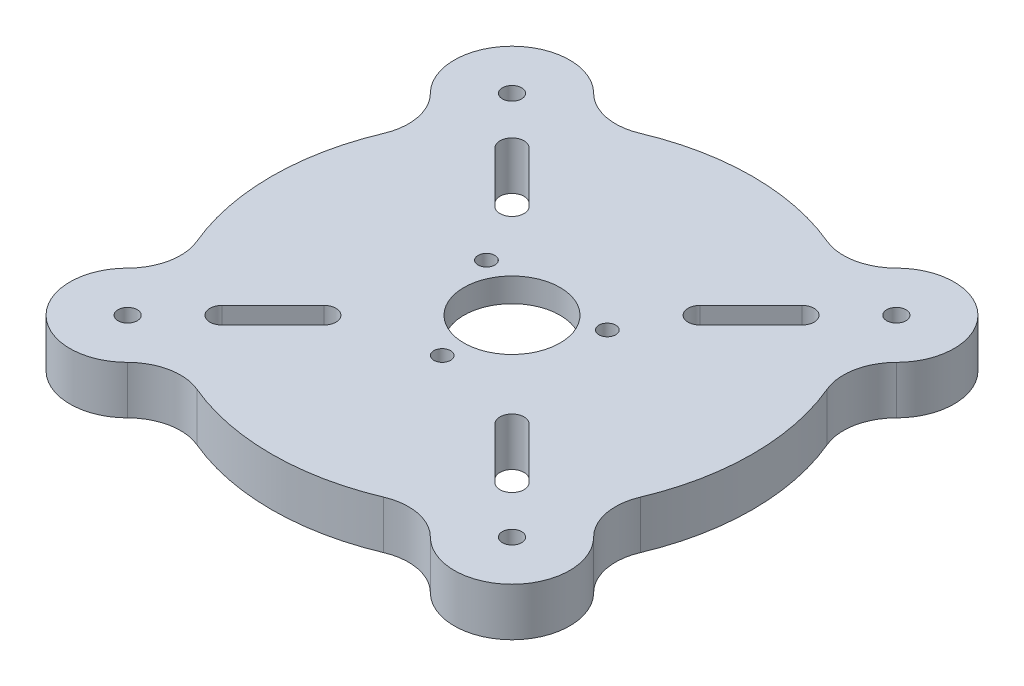
from build123d import *

# Parameters (mm, degrees)
SKETCH1_R           = 2
BOSS_EXTRUDE1_DEPTH = 10
SKETCH3_R           = 21
CUT_EXTRUDE2_DEPTH  = 5
SKETCH3_4_R         = 1.75
CUT_EXTRUDE3_DEPTH  = 75.1479844
SKETCH3_5_R         = 10
CUT_EXTRUDE4_DEPTH  = 75.1479844


with BuildPart() as part:
    # Sketch1 → Boss-Extrude1 (new body)
    with BuildSketch(Plane(origin=(0, 0, 0), x_dir=(1, 0, 0), z_dir=(0, 1, 0))):
        with BuildLine():
            ThreePointArc((46.077281732, -19.413503243), (50, 0), (46.077281732, 19.413503243))
            ThreePointArc((46.077281732, 19.413503243), (45.41900176, 25.799706685), (48.436814511, 31.466251763))
            ThreePointArc((48.436814511, 31.466251763), (48.436814511, 48.436814511), (31.466251763, 48.436814511))
            ThreePointArc((31.466251763, 48.436814511), (25.799706685, 45.41900176), (19.413503243, 46.077281732))
            ThreePointArc((19.413503243, 46.077281732), (0, 50), (-19.413503243, 46.077281732))
            ThreePointArc((-19.413503243, 46.077281732), (-25.799706685, 45.41900176), (-31.466251763, 48.436814511))
            ThreePointArc((-31.466251763, 48.436814511), (-48.436814511, 48.436814511), (-48.436814511, 31.466251763))
            ThreePointArc((-48.436814511, 31.466251763), (-45.41900176, 25.799706685), (-46.077281732, 19.413503243))
            ThreePointArc((-46.077281732, 19.413503243), (-50, 0), (-46.077281732, -19.413503243))
            ThreePointArc((-46.077281732, -19.413503243), (-45.41900176, -25.799706685), (-48.436814511, -31.466251763))
            ThreePointArc((-48.436814511, -31.466251763), (-48.436814511, -48.436814511), (-31.466251763, -48.436814511))
            ThreePointArc((-31.466251763, -48.436814511), (-25.799706685, -45.41900176), (-19.413503243, -46.077281732))
            ThreePointArc((-19.413503243, -46.077281732), (0, -50), (19.413503243, -46.077281732))
            ThreePointArc((19.413503243, -46.077281732), (25.799706685, -45.41900176), (31.466251763, -48.436814511))
            ThreePointArc((31.466251763, -48.436814511), (48.436814511, -48.436814511), (48.436814511, -31.466251763))
            ThreePointArc((48.436814511, -31.466251763), (45.41900176, -25.799706685), (46.077281732, -19.413503243))
        make_face()
        with BuildLine():
            Line((-31.921022838, -28.385488932), (-21.31442112, -17.778887214))
            ThreePointArc((-21.31442112, -17.778887214), (-17.778887214, -17.778887214), (-17.778887214, -21.31442112))
            Line((-17.778887214, -21.31442112), (-28.385488932, -31.921022838))
            ThreePointArc((-28.385488932, -31.921022838), (-31.921022838, -31.921022838), (-31.921022838, -28.385488932))
        make_face(mode=Mode.SUBTRACT)
        with BuildLine():
            Line((28.385488932, -31.921022838), (17.778887214, -21.31442112))
            ThreePointArc((17.778887214, -21.31442112), (17.778887214, -17.778887214), (21.31442112, -17.778887214))
            Line((21.31442112, -17.778887214), (31.921022838, -28.385488932))
            ThreePointArc((31.921022838, -28.385488932), (31.921022838, -31.921022838), (28.385488932, -31.921022838))
        make_face(mode=Mode.SUBTRACT)
        with BuildLine():
            Line((-28.385488932, 31.921022838), (-17.778887214, 21.31442112))
            ThreePointArc((-17.778887214, 21.31442112), (-17.778887214, 17.778887214), (-21.31442112, 17.778887214))
            Line((-21.31442112, 17.778887214), (-31.921022838, 28.385488932))
            ThreePointArc((-31.921022838, 28.385488932), (-31.921022838, 31.921022838), (-28.385488932, 31.921022838))
        make_face(mode=Mode.SUBTRACT)
        with BuildLine():
            ThreePointArc((21.31442112, 17.778887214), (17.778887214, 17.778887214), (17.778887214, 21.31442112))
            Line((17.778887214, 21.31442112), (28.385488932, 31.921022838))
            ThreePointArc((28.385488932, 31.921022838), (31.921022838, 31.921022838), (31.921022838, 28.385488932))
            Line((31.921022838, 28.385488932), (21.31442112, 17.778887214))
        make_face(mode=Mode.SUBTRACT)
        with Locations((39.951533137, -39.951533137)):
            Circle(SKETCH1_R, mode=Mode.SUBTRACT)
        with Locations((-39.951533137, -39.951533137)):
            Circle(SKETCH1_R, mode=Mode.SUBTRACT)
        with Locations((-39.951533137, 39.951533137)):
            Circle(SKETCH1_R, mode=Mode.SUBTRACT)
        with Locations((39.951533137, 39.951533137)):
            Circle(SKETCH1_R, mode=Mode.SUBTRACT)
    extrude(amount=BOSS_EXTRUDE1_DEPTH)

    # Sketch3 → Cut-Extrude2 (cut)
    with BuildSketch(Plane.XZ):
        Circle(SKETCH3_R)
    extrude(amount=-CUT_EXTRUDE2_DEPTH, mode=Mode.SUBTRACT)

    # Sketch3_4 → Cut-Extrude3 (cut, through all)
    with BuildSketch(Plane.XZ):
        with Locations((0, 14.5)):
            Circle(SKETCH3_4_R)
        with Locations((12.557368355, -7.25)):
            Circle(SKETCH3_4_R)
        with Locations((-12.557368355, -7.25)):
            Circle(SKETCH3_4_R)
    extrude(amount=-CUT_EXTRUDE3_DEPTH, mode=Mode.SUBTRACT)

    # Sketch3_5 → Cut-Extrude4 (cut, through all)
    with BuildSketch(Plane.XZ):
        Circle(SKETCH3_5_R)
    extrude(amount=-CUT_EXTRUDE4_DEPTH, mode=Mode.SUBTRACT)


solid = part.part
